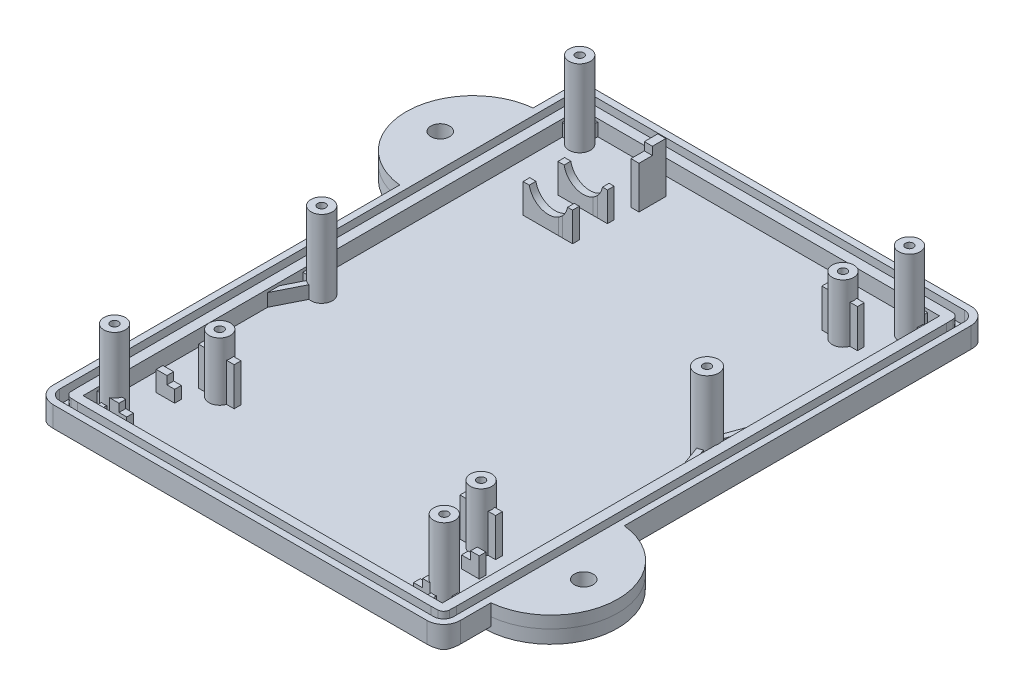
from build123d import *

# Parameters (mm, degrees)
BOSS_EXTRUDE1_DEPTH     = 1.6
BOSS_EXTRUDE2_DEPTH     = 3.95
CHAMFER1_SIZE           = 2.45
CHAMFER1_SIZE2          = 0.88
FILLET1_R               = 2.49
FILLET2_R               = 2.49
CUT_EXTRUDE2_DEPTH      = 2
BOSS_EXTRUDE5_DEPTH     = 5.95
CUT_EXTRUDE3_DEPTH      = 7
SKETCH8_W               = 1.2
SKETCH8_H               = 4
BOSS_EXTRUDE6_DEPTH     = 7.9
SKETCH8_3_W             = 1.2
SKETCH8_3_H             = 2
BOSS_EXTRUDE7_DEPTH     = 9.1
SKETCH10_W              = 1.3
SKETCH10_H              = 1
SKETCH10_W_2            = 1.35
SKETCH10_W_3            = 1.6
SKETCH10_W_4            = 1.15
BOSS_EXTRUDE8_DEPTH     = 3.4
SKETCH10_3_W            = 1.6
SKETCH10_3_H            = 1
SKETCH10_3_W_2          = 1.3
BOSS_EXTRUDE9_DEPTH     = 4.6
SKETCH11_R              = 1.6
SKETCH11_R_2            = 1.09996433
SKETCH11_R_3            = 0.6
BOSS_EXTRUDE10_DEPTH    = 10.3
BOSS_EXTRUDE11_DEPTH    = 7.3
SKETCH13_R              = 1.6
SKETCH13_R_2            = 0.6
SKETCH13_R_3            = 1.75
BOSS_EXTRUDE12_DEPTH    = 13.1
BOSS_EXTRUDE13_DEPTH    = 3.5
SKETCH15_R              = 1.4
BOSS_EXTRUDE14_DEPTH    = 1.8
SKETCH16_R              = 1.4
SKETCH16_W              = 2.732941719
SKETCH16_H              = 1.2
BOSS_EXTRUDE17_DEPTH    = 2
SKETCH16_7_R            = 1.4
CUT_EXTRUDE4_DEPTH      = 3.1500001
CUT_EXTRUDE4_DEPTH_BACK = 11.95


with BuildPart() as part:
    # Sketch2 → Boss-Extrude1 (new body)
    with BuildSketch(Plane(origin=(0, 0, 0), x_dir=(1, 0, 0), z_dir=(0, 1, 0))):
        Polygon((61.101618414, 26.013534869), (61.101618414, -0.9363395), (0.312094646, -0.9363395), (0.312094646, 53.303309896), (0.312094646, 80.253184266), (61.101618414, 80.253184266), align=None)
    extrude(amount=BOSS_EXTRUDE1_DEPTH)

    # Sketch3 → Boss-Extrude2 (add)
    with BuildSketch(Plane(origin=(0, 0, 0), x_dir=(1, 0, 0), z_dir=(0, 1, 0))):
        Polygon((61.101618414, 80.253184266), (61.101618414, 26.013534869), (61.101618414, -0.9363395), (0.312094646, -0.9363395), (0.312094646, 80.253184266), align=None)
        Polygon((57.50685653, 44.073753576), (57.50685653, 2.458422382), (3.90685653, 2.458422382), (3.90685653, 76.658422382), (57.50685653, 76.658422382), align=None, mode=Mode.SUBTRACT)
    extrude(amount=BOSS_EXTRUDE2_DEPTH)

    # Chamfer1
    chamfer1_edges = [part.edges().sort_by_distance(p)[0] for p in [
        (61.101618414, 0, -39.658422383),
        (30.70685653, 0, 0.9363395),
        (0.312094646, 0, -39.658422383),
        (30.70685653, 0, -80.253184266),
    ]]
    chamfer1_side = [part.faces().sort_by_distance(p)[0] for p in [
        (30.70685653, 0, -39.658422383),
    ]]
    chamfer(chamfer1_edges, length=CHAMFER1_SIZE, length2=CHAMFER1_SIZE2, reference=chamfer1_side[0])

    # Fillet1
    fillet1_edges = [part.edges().sort_by_distance(p)[0] for p in [
        (61.101618414, 2.415, 0.9363395),
        (0.312094646, 2.415, 0.9363395),
        (0.312094646, 2.415, -80.253184266),
        (61.101618414, 2.415, -80.253184266),
    ]]
    fillet(fillet1_edges, radius=FILLET1_R)

    # Fillet2
    fillet2_edges = [part.edges().sort_by_distance(p)[0] for p in [
        (59.511966357, 0.309022934, -78.663532209),
        (1.901746703, 0.309022934, -78.663532209),
        (59.511966357, 0.309022934, -0.653312557),
        (1.901746703, 0.309022934, -0.653312557),
    ]]
    fillet(fillet2_edges, radius=FILLET2_R)

    # Sketch4 → Cut-Extrude2 (cut)
    with BuildSketch(Plane(origin=(0, 3.95, 0), x_dir=(1, 0, 0), z_dir=(0, 1, 0))):
        with BuildLine():
            Line((1.306856531, 77.758381947), (1.306856531, 1.558338249))
            ThreePointArc((1.306856531, 1.558338249), (1.746196171, 0.497762396), (2.80677187, 0.058422385))
            Line((2.80677187, 0.058422385), (58.60694295, 0.058422385))
            ThreePointArc((58.60694295, 0.058422385), (59.667577413, 0.497822924), (60.106856529, 1.558507681))
            Line((60.106856529, 1.558507681), (60.106856529, 77.758468586))
            ThreePointArc((60.106856529, 77.758468586), (59.667502452, 78.819096804), (58.606862429, 79.258422382))
            Line((58.606862429, 79.258422382), (2.806815574, 79.258422382))
            ThreePointArc((2.806815574, 79.258422382), (1.746167583, 78.819053778), (1.306856531, 77.758381947))
        make_face()
        with BuildLine():
            Line((2.451145187, 3.109951903), (2.451145187, 76.20688467))
            ThreePointArc((2.451145187, 76.20688467), (2.465707483, 76.721124826), (2.481091711, 77.23534105))
            add(Edge.make_bspline(
                [(2.481091711, 77.23534105), (2.48444708, 77.344456562), (2.53535597, 77.563663952), (2.725774736, 77.83950736), (3.001615387, 78.029927982), (3.220824656, 78.080845559), (3.329941999, 78.084191338)],
                knots=[0, 0, 0, 0, 0.249690979, 0.499999572, 0.750305511, 1, 1, 1, 1], degree=3))
            ThreePointArc((3.329941999, 78.084191338), (3.844154324, 78.099568382), (4.358390285, 78.114133592))
            Line((4.358390285, 78.114133592), (57.055323052, 78.114133592))
            ThreePointArc((57.055323052, 78.114133592), (57.569563314, 78.099571683), (58.083779644, 78.084187842))
            add(Edge.make_bspline(
                [(58.083779644, 78.084187842), (58.192895878, 78.080847066), (58.412105536, 78.029921737), (58.687945128, 77.839504809), (58.878368087, 77.563660833), (58.929271149, 77.344453812), (58.932629932, 77.235337554)],
                knots=[0, 0, 0, 0, 0.249691647, 0.50000206, 0.750307036, 1, 1, 1, 1], degree=3))
            ThreePointArc((58.932629932, 77.235337554), (58.948007789, 76.721125241), (58.962573811, 76.206889291))
            Line((58.962573811, 76.206889291), (58.962573811, 3.109956599))
            ThreePointArc((58.962573811, 3.109956599), (58.948011797, 2.595716427), (58.93262785, 2.081500188))
            add(Edge.make_bspline(
                [(58.93262785, 2.081500188), (58.929287074, 1.972383954), (58.878361746, 1.753174295), (58.687944817, 1.477334703), (58.412100841, 1.286911744), (58.19289382, 1.236008683), (58.083777562, 1.2326499)],
                knots=[0, 0, 0, 0, 0.249691647, 0.50000206, 0.750307036, 1, 1, 1, 1], degree=3))
            ThreePointArc((58.083777562, 1.2326499), (57.569561957, 1.217274714), (57.05532272, 1.202711372))
            Line((57.05532272, 1.202711372), (4.358396351, 1.202711372))
            ThreePointArc((4.358396351, 1.202711372), (3.844155104, 1.217271394), (3.329937787, 1.232653351))
            add(Edge.make_bspline(
                [(3.329937787, 1.232653351), (3.220821553, 1.235994128), (3.001611894, 1.286919456), (2.725772302, 1.477336384), (2.535349343, 1.75318036), (2.484446282, 1.972387381), (2.481087499, 2.081503639)],
                knots=[0, 0, 0, 0, 0.249691647, 0.50000206, 0.750307036, 1, 1, 1, 1], degree=3))
            ThreePointArc((2.481087499, 2.081503639), (2.465710426, 2.595715953), (2.451145187, 3.109951903))
        make_face(mode=Mode.SUBTRACT)
    extrude(amount=-CUT_EXTRUDE2_DEPTH, mode=Mode.SUBTRACT)

    # Sketch1 → Boss-Extrude5 (add)
    with BuildSketch(Plane(origin=(0, 0, 0), x_dir=(1, 0, 0), z_dir=(0, 1, 0))):
        Polygon((11.064797943, 67.148179897), (11.064797943, 66.148179898), (16.334665191, 66.148174719), (16.957390288, 66.14818838), (18.45685653, 66.14818838), (18.45685653, 67.14818838), (16.957390288, 67.14818838), (16.334536657, 67.148174717), align=None)
        Polygon((11.064797943, 61.948179898), (11.064797943, 60.948179898), (16.335333194, 60.94817473), (16.957390288, 60.948188381), (18.45685653, 60.948188381), (18.45685653, 61.94818838), (16.957390288, 61.94818838), (16.335204781, 61.948174728), align=None)
    extrude(amount=BOSS_EXTRUDE5_DEPTH)

    # Sketch7 → Cut-Extrude3 (cut)
    with BuildSketch(Plane(origin=(5.9765e-05, 0, -60.948190748), x_dir=(1, 0, 9.81e-07), z_dir=(-9.81e-07, 0, 1))):
        with BuildLine():
            Line((11.991843246, 5.95), (11.991843246, 7.530496652))
            Line((11.991843246, 7.530496652), (17.707063644, 7.530496652))
            Line((17.707063644, 7.530496652), (17.707063644, 5.95))
            ThreePointArc((17.707063644, 5.95), (14.849453445, 3.573186549), (11.991843246, 5.95))
        make_face()
    extrude(amount=-CUT_EXTRUDE3_DEPTH, mode=Mode.SUBTRACT)

    # Sketch8 → Boss-Extrude6 (add)
    with BuildSketch(Plane(origin=(0, 0, 0), x_dir=(1, 0, 0), z_dir=(0, 1, 0))):
        with Locations((18.70685653, 72.008422382)):
            Rectangle(SKETCH8_W, SKETCH8_H)
    extrude(amount=BOSS_EXTRUDE6_DEPTH)

    # Sketch8_3 → Boss-Extrude7 (add)
    with BuildSketch(Plane(origin=(0, 0, 0), x_dir=(1, 0, 0), z_dir=(0, 1, 0))):
        with Locations((18.70685653, 73.008422382)):
            Rectangle(SKETCH8_3_W, SKETCH8_3_H)
    extrude(amount=BOSS_EXTRUDE7_DEPTH)

    # Sketch10 → Boss-Extrude8 (add)
    with BuildSketch(Plane(origin=(0, 0, 0), x_dir=(1, 0, 0), z_dir=(0, 1, 0))):
        with Locations((54.169803613, 11.158422382)):
            Rectangle(SKETCH10_W, SKETCH10_H)
        with Locations((52.844803613, 11.158422382)):
            Rectangle(SKETCH10_W_2, SKETCH10_H)
        with Locations((7.419803613, 11.158422382)):
            Rectangle(SKETCH10_W_3, SKETCH10_H)
        with Locations((8.794803613, 11.158422382)):
            Rectangle(SKETCH10_W_4, SKETCH10_H)
        with Locations((52.844803613, 4.008422382)):
            Rectangle(SKETCH10_W_2, SKETCH10_H)
        with BuildLine():
            Line((53.771441277, 4.508422382), (53.519803613, 4.508422382))
            Line((53.519803613, 4.508422382), (53.519803613, 3.508422382))
            Line((53.519803613, 3.508422382), (54.630469067, 3.508422382))
            ThreePointArc((54.630469067, 3.508422382), (54.093177078, 3.915838004), (53.771441277, 4.508422382))
        make_face()
        with BuildLine():
            ThreePointArc((7.642271784, 4.508422382), (7.320535983, 3.915838004), (6.783243993, 3.508422382))
            Line((6.783243993, 3.508422382), (8.219803613, 3.508422382))
            Line((8.219803613, 3.508422382), (8.219803613, 4.508422382))
            Line((8.219803613, 4.508422382), (7.642271784, 4.508422382))
        make_face()
        with Locations((8.794803613, 4.008422382)):
            Rectangle(SKETCH10_W_4, SKETCH10_H)
    extrude(amount=BOSS_EXTRUDE8_DEPTH)

    # Sketch10_3 → Boss-Extrude9 (add)
    with BuildSketch(Plane(origin=(0, 0, 0), x_dir=(1, 0, 0), z_dir=(0, 1, 0))):
        with Locations((7.419803613, 11.158422382)):
            Rectangle(SKETCH10_3_W, SKETCH10_3_H)
        with Locations((54.169803613, 11.158422382)):
            Rectangle(SKETCH10_3_W_2, SKETCH10_3_H)
        with BuildLine():
            Line((53.771441277, 4.508422382), (53.519803613, 4.508422382))
            Line((53.519803613, 4.508422382), (53.519803613, 3.508422382))
            Line((53.519803613, 3.508422382), (54.630469067, 3.508422382))
            ThreePointArc((54.630469067, 3.508422382), (54.093177078, 3.915838004), (53.771441277, 4.508422382))
        make_face()
        with BuildLine():
            ThreePointArc((7.642271784, 4.508422382), (7.320535983, 3.915838004), (6.783243993, 3.508422382))
            Line((6.783243993, 3.508422382), (8.219803613, 3.508422382))
            Line((8.219803613, 3.508422382), (8.219803613, 4.508422382))
            Line((8.219803613, 4.508422382), (7.642271784, 4.508422382))
        make_face()
    extrude(amount=BOSS_EXTRUDE9_DEPTH)

    # Sketch11 → Boss-Extrude10 (add)
    with BuildSketch(Plane(origin=(0, 0, 0), x_dir=(1, 0, 0), z_dir=(0, 1, 0))):
        with Locations((11.869803613, 14.885183898)):
            Circle(SKETCH11_R)
        with Locations((11.869803613, 14.885183898)):
            Circle(SKETCH11_R_2, mode=Mode.SUBTRACT)
        with Locations((11.869803613, 14.885183898)):
            Circle(SKETCH11_R_2)
        with Locations((11.869803613, 14.885183898)):
            Circle(SKETCH11_R_3, mode=Mode.SUBTRACT)
        with Locations((50.869803613, 14.885183898)):
            Circle(SKETCH11_R)
        with Locations((50.869803613, 14.885183898)):
            Circle(SKETCH11_R_2, mode=Mode.SUBTRACT)
        with Locations((50.869803613, 14.885183898)):
            Circle(SKETCH11_R_2)
        with Locations((50.869803613, 14.885183898)):
            Circle(SKETCH11_R_3, mode=Mode.SUBTRACT)
        with Locations((50.869803613, 68.885183898)):
            Circle(SKETCH11_R)
        with Locations((50.869803613, 68.885183898)):
            Circle(SKETCH11_R_2, mode=Mode.SUBTRACT)
        with Locations((50.869803613, 68.885183898)):
            Circle(SKETCH11_R_2)
        with Locations((50.869803613, 68.885183898)):
            Circle(SKETCH11_R_3, mode=Mode.SUBTRACT)
    extrude(amount=BOSS_EXTRUDE10_DEPTH)

    # Sketch12 → Boss-Extrude11 (add)
    with BuildSketch(Plane(origin=(0, 0, 0), x_dir=(1, 0, 0), z_dir=(0, 1, 0))):
        with BuildLine():
            Line((48.208266697, 14.385183898), (49.349935198, 14.385183898))
            ThreePointArc((49.349935198, 14.385183898), (49.269803613, 14.885183898), (49.349935198, 15.385183898))
            Line((49.349935198, 15.385183898), (48.208266697, 15.385183898))
            Line((48.208266697, 15.385183898), (48.208266697, 14.385183898))
        make_face()
        with BuildLine():
            Line((52.389672028, 14.385183898), (53.531340529, 14.385183898))
            Line((53.531340529, 14.385183898), (53.531340529, 15.385183898))
            Line((53.531340529, 15.385183898), (52.389672028, 15.385183898))
            ThreePointArc((52.389672028, 15.385183898), (52.44964371, 15.138374079), (52.469803613, 14.885183898))
            ThreePointArc((52.469803613, 14.885183898), (52.44964371, 14.631993717), (52.389672028, 14.385183898))
        make_face()
        with BuildLine():
            Line((9.208266697, 14.378220377), (10.352243734, 14.378220377))
            ThreePointArc((10.352243734, 14.378220377), (10.269803613, 14.885183898), (10.352243734, 15.392147419))
            Line((10.352243734, 15.392147419), (9.208266697, 15.392147419))
            Line((9.208266697, 15.392147419), (9.208266697, 14.378220377))
        make_face()
        with BuildLine():
            Line((13.387363493, 14.378220377), (14.531340529, 14.378220377))
            Line((14.531340529, 14.378220377), (14.531340529, 15.392147419))
            Line((14.531340529, 15.392147419), (13.387363493, 15.392147419))
            ThreePointArc((13.387363493, 15.392147419), (13.449059103, 15.1419953), (13.469803613, 14.885183898))
            ThreePointArc((13.469803613, 14.885183898), (13.449059103, 14.628372496), (13.387363493, 14.378220377))
        make_face()
        with BuildLine():
            Line((53.531340529, 68.385183898), (53.531340529, 69.385183898))
            Line((53.531340529, 69.385183898), (52.389672028, 69.385183898))
            ThreePointArc((52.389672028, 69.385183898), (52.44964371, 69.138374079), (52.469803613, 68.885183898))
            ThreePointArc((52.469803613, 68.885183898), (52.44964371, 68.631993717), (52.389672028, 68.385183898))
            Line((52.389672028, 68.385183898), (53.531340529, 68.385183898))
        make_face()
        with BuildLine():
            ThreePointArc((49.349935198, 68.385183898), (49.269803613, 68.885183898), (49.349935198, 69.385183898))
            Line((49.349935198, 69.385183898), (48.208266697, 69.385183898))
            Line((48.208266697, 69.385183898), (48.208266697, 68.385183898))
            Line((48.208266697, 68.385183898), (49.349935198, 68.385183898))
        make_face()
    extrude(amount=BOSS_EXTRUDE11_DEPTH)

    # Sketch13 → Boss-Extrude12 (add)
    with BuildSketch(Plane(origin=(0, 0, 0), x_dir=(1, 0, 0), z_dir=(0, 1, 0))):
        with Locations((55.30685653, 74.358422382)):
            Circle(SKETCH13_R)
        with Locations((55.30685653, 74.358422382)):
            Circle(SKETCH13_R_2, mode=Mode.SUBTRACT)
        with Locations((6.10685653, 74.358422382)):
            Circle(SKETCH13_R)
        with Locations((6.10685653, 74.358422382)):
            Circle(SKETCH13_R_2, mode=Mode.SUBTRACT)
        with Locations((55.80685653, 43.658422382)):
            Circle(SKETCH13_R_3)
        with Locations((55.80685653, 43.658422382)):
            Circle(SKETCH13_R_2, mode=Mode.SUBTRACT)
        with Locations((55.30685653, 4.958422382)):
            Circle(SKETCH13_R)
        with Locations((55.30685653, 4.958422382)):
            Circle(SKETCH13_R_2, mode=Mode.SUBTRACT)
        with Locations((6.10685653, 4.958422382)):
            Circle(SKETCH13_R)
        with Locations((6.10685653, 4.958422382)):
            Circle(SKETCH13_R_2, mode=Mode.SUBTRACT)
        with Locations((6.30685653, 35.658422382)):
            Circle(SKETCH13_R)
        with Locations((6.30685653, 35.658422382)):
            Circle(SKETCH13_R_2, mode=Mode.SUBTRACT)
    extrude(amount=BOSS_EXTRUDE12_DEPTH)

    # Sketch14 → Boss-Extrude13 (add)
    with BuildSketch(Plane(origin=(0, 0, 0), x_dir=(1, 0, 0), z_dir=(0, 1, 0))):
        with BuildLine():
            Line((3.90685653, 5.358422382), (3.90685653, 4.558422382))
            Line((3.90685653, 4.558422382), (4.557663192, 4.558422382))
            ThreePointArc((4.557663192, 4.558422382), (4.50685653, 4.958422382), (4.557663192, 5.358422382))
            Line((4.557663192, 5.358422382), (3.90685653, 5.358422382))
        make_face()
        with BuildLine():
            ThreePointArc((6.50685653, 3.409229044), (6.10685653, 3.358422382), (5.70685653, 3.409229044))
            Line((5.70685653, 3.409229044), (5.70685653, 2.458422382))
            Line((5.70685653, 2.458422382), (6.50685653, 2.458422382))
            Line((6.50685653, 2.458422382), (6.50685653, 3.409229044))
        make_face()
        with BuildLine():
            Line((3.90685653, 31.767811418), (3.90685653, 29.984196998))
            Line((3.90685653, 29.984196998), (5.969508443, 34.094390328))
            ThreePointArc((5.969508443, 34.094390328), (5.589212635, 34.228391879), (5.254493191, 34.453212276))
            Line((5.254493191, 34.453212275), (3.90685653, 31.767811418))
        make_face()
        with BuildLine():
            Line((3.90685653, 36.058422382), (3.90685653, 35.258422382))
            Line((3.90685653, 35.258422382), (4.757663192, 35.258422382))
            ThreePointArc((4.757663192, 35.258422382), (4.70685653, 35.658422382), (4.757663192, 36.058422382))
            Line((4.757663192, 36.058422382), (3.90685653, 36.058422382))
        make_face()
        with BuildLine():
            Line((3.90685653, 74.758422382), (3.90685653, 73.958422382))
            Line((3.90685653, 73.958422382), (4.557663192, 73.958422382))
            ThreePointArc((4.557663192, 73.958422382), (4.50685653, 74.358422382), (4.557663192, 74.758422382))
            Line((4.557663192, 74.758422382), (3.90685653, 74.758422382))
        make_face()
        with BuildLine():
            Line((6.50685653, 76.658422382), (5.70685653, 76.658422382))
            Line((5.70685653, 76.658422382), (5.70685653, 75.907615721))
            ThreePointArc((5.70685653, 75.907615721), (6.10685653, 75.958422382), (6.50685653, 75.907615721))
            Line((6.50685653, 75.907615721), (6.50685653, 76.658422382))
        make_face()
        with BuildLine():
            Line((55.70685653, 76.658422382), (54.90685653, 76.658422382))
            Line((54.90685653, 76.658422382), (54.90685653, 75.907615721))
            ThreePointArc((54.90685653, 75.907615721), (55.30685653, 75.958422382), (55.70685653, 75.907615721))
            Line((55.70685653, 75.907615721), (55.70685653, 76.658422382))
        make_face()
        with BuildLine():
            Line((56.856049869, 73.958422382), (57.50685653, 73.958422382))
            Line((57.50685653, 73.958422382), (57.50685653, 74.758422382))
            Line((57.50685653, 74.758422382), (56.856049869, 74.758422382))
            ThreePointArc((56.856049869, 74.758422382), (56.894104044, 74.56002925), (56.90685653, 74.358422382))
            ThreePointArc((56.90685653, 74.358422382), (56.894104044, 74.156815514), (56.856049869, 73.958422382))
        make_face()
        with BuildLine():
            Line((56.013669796, 41.920685845), (57.50685653, 37.818189009))
            Line((57.50685653, 37.818189009), (57.50685653, 40.157232529))
            Line((57.50685653, 40.157232529), (56.765423893, 42.19430196))
            ThreePointArc((56.765423893, 42.19430196), (56.405391781, 42.013960296), (56.013669796, 41.920685845))
        make_face()
        with BuildLine():
            Line((57.50685653, 49.498655756), (56.013669796, 45.39615892))
            ThreePointArc((56.013669796, 45.39615892), (56.405391781, 45.302884469), (56.765423893, 45.122542805))
            Line((56.765423893, 45.122542805), (57.50685653, 47.159612235))
            Line((57.50685653, 47.159612235), (57.50685653, 49.498655756))
        make_face()
        with BuildLine():
            Line((54.90685653, 3.409229044), (54.90685653, 2.458422382))
            Line((54.90685653, 2.458422382), (55.70685653, 2.458422382))
            Line((55.70685653, 2.458422382), (55.70685653, 3.409229044))
            ThreePointArc((55.70685653, 3.409229044), (55.30685653, 3.358422382), (54.90685653, 3.409229044))
        make_face()
        with BuildLine():
            Line((57.50685653, 5.358422382), (56.856049869, 5.358422382))
            ThreePointArc((56.856049869, 5.358422382), (56.894104044, 5.16002925), (56.90685653, 4.958422382))
            ThreePointArc((56.90685653, 4.958422382), (56.894104044, 4.756815514), (56.856049869, 4.558422382))
            Line((56.856049869, 4.558422382), (57.50685653, 4.558422382))
            Line((57.50685653, 4.558422382), (57.50685653, 5.358422382))
        make_face()
    extrude(amount=BOSS_EXTRUDE13_DEPTH)



with BuildPart() as body_2:
    # Sketch15 → Boss-Extrude14 (new body)
    with BuildSketch(Plane(origin=(0, 3.95, 0), x_dir=(1, 0, 0), z_dir=(0, 1, 0))):
        with BuildLine():
            ThreePointArc((0.312094646, 73.203058637), (-8.687905355, 63.253184266), (0.312094646, 53.303309895))
            Line((0.312094646, 53.303309895), (0.312094646, 73.203058637))
        make_face()
        with Locations((-3.59314347, 63.253184266)):
            Circle(SKETCH15_R, mode=Mode.SUBTRACT)
        with BuildLine():
            Line((61.101618415, 26.013534868), (61.101618415, 6.113786126))
            ThreePointArc((61.101618415, 6.113786126), (70.101618415, 16.063660497), (61.101618415, 26.013534868))
        make_face()
        with Locations((65.00685653, 16.063660497)):
            Circle(SKETCH15_R, mode=Mode.SUBTRACT)
        with Locations((65.00685653, 16.063660497)):
            Circle(SKETCH15_R)
        with Locations((-3.59314347, 63.253184266)):
            Circle(SKETCH15_R)
    extrude(amount=-BOSS_EXTRUDE14_DEPTH)


with BuildPart() as part_1:
    add(part.part)

    add(body_2.part)  # Boss-Extrude17 merges body 2
    # Sketch16 → Boss-Extrude17 (add)
    with BuildSketch(Plane.XZ.offset(-2.15)):
        with BuildLine():
            Line((0.312094646, -73.202297396), (0.312094646, -71.996453446))
            ThreePointArc((0.312094646, -71.996453446), (-5.0507909, -69.332099104), (-7.467594845, -63.853195552))
            Line((-7.467594845, -63.853195552), (-6.532531161, -63.853184269))
            ThreePointArc((-6.532531161, -63.853184269), (-3.59314347, -66.253184269), (-0.653755779, -63.853184269))
            Line((-0.653755779, -63.853184269), (0.312094646, -63.853184269))
            Line((0.312094646, -63.853184269), (0.312094646, -62.653184269))
            Line((0.312094646, -62.653184269), (-0.653755779, -62.653184269))
            ThreePointArc((-0.653755779, -62.653184269), (-3.59314347, -60.253184269), (-6.532531161, -62.653184269))
            Line((-6.532531161, -62.653184269), (-7.468907762, -62.653083066))
            ThreePointArc((-7.468907762, -62.653083066), (-5.052094597, -57.172506361), (0.312094646, -54.507327068))
            Line((0.312094646, -54.507327068), (0.312094646, -53.303309895))
            ThreePointArc((0.312094646, -53.303309895), (-2.526848583, -54.019413916), (-5.036702104, -55.527074001))
            ThreePointArc((-5.036702104, -55.527074001), (-8.25842528, -66.148943531), (0.312094646, -73.202297396))
        make_face()
        with Locations((-3.59314347, -63.253184269)):
            Circle(SKETCH16_R, mode=Mode.SUBTRACT)
        with Locations((1.678565505, -63.253184269)):
            Rectangle(SKETCH16_W, SKETCH16_H)
        with BuildLine():
            ThreePointArc((3.049053855, -53.404367142), (-1.226280578, -53.580253909), (-5.036702104, -55.527074001))
            ThreePointArc((-5.036702104, -55.527074001), (-2.526848583, -54.019413916), (0.312094646, -53.303309895))
            Line((0.312094646, -53.303309895), (0.312094646, -54.507327068))
            ThreePointArc((0.312094646, -54.507327068), (1.68502091, -54.458113085), (3.04888308, -54.623123757))
            Line((3.04888308, -54.623123757), (3.049053855, -53.404367142))
        make_face()
        with BuildLine():
            Line((3.046293896, -73.101131026), (3.016110468, -71.887169301))
            ThreePointArc((3.016110468, -71.887169301), (1.668328137, -72.046364838), (0.312094646, -71.996453446))
            Line((0.312094646, -71.996453446), (0.312094646, -73.202297396))
            ThreePointArc((0.312094646, -73.202297396), (1.682670591, -73.245667892), (3.046293896, -73.101131026))
        make_face()
        with BuildLine():
            ThreePointArc((68.881329369, -16.663668361), (65.450022252, -23.084299301), (58.365594427, -24.760381813))
            Line((58.365594427, -24.760381813), (58.365410272, -25.928459311))
            ThreePointArc((58.365410272, -25.928459311), (70.050388092, -16.073015567), (58.368518398, -6.213887892))
            Line((58.368518398, -6.213887892), (58.368326875, -7.428699868))
            ThreePointArc((58.368326875, -7.428699868), (65.413489938, -9.088358735), (68.834508435, -15.466871301))
            Line((68.834508435, -15.466871301), (67.946244221, -15.4636605))
            ThreePointArc((67.946244221, -15.4636605), (65.00685653, -13.0636605), (62.067468839, -15.4636605))
            Line((62.067468839, -15.4636605), (58.368676695, -15.4636605))
            Line((58.368676695, -15.4636605), (58.368676695, -16.6636605))
            Line((58.368676695, -16.6636605), (62.067468839, -16.6636605))
            ThreePointArc((62.067468839, -16.6636605), (65.00685653, -19.0636605), (67.946244221, -16.6636605))
            Line((67.946244221, -16.6636605), (68.881329369, -16.663668361))
        make_face()
        with Locations((65.00685653, -16.0636605)):
            Circle(SKETCH16_R, mode=Mode.SUBTRACT)
        with Locations((-3.59314347, -63.253184269)):
            Circle(SKETCH16_R)
        with Locations((65.00685653, -16.0636605)):
            Circle(SKETCH16_R)
    extrude(amount=BOSS_EXTRUDE17_DEPTH)

    # Sketch16_7 → Cut-Extrude4 (cut, two sides)
    with BuildSketch(Plane.XZ.offset(-2.15)) as cut_extrude4_sk:
        with Locations((-3.59314347, -63.253184269)):
            Circle(SKETCH16_7_R)
        with Locations((65.00685653, -16.0636605)):
            Circle(SKETCH16_7_R)
    extrude(amount=CUT_EXTRUDE4_DEPTH, mode=Mode.SUBTRACT)
    extrude(cut_extrude4_sk.sketch, amount=-CUT_EXTRUDE4_DEPTH_BACK, mode=Mode.SUBTRACT)


solid = part_1.part
